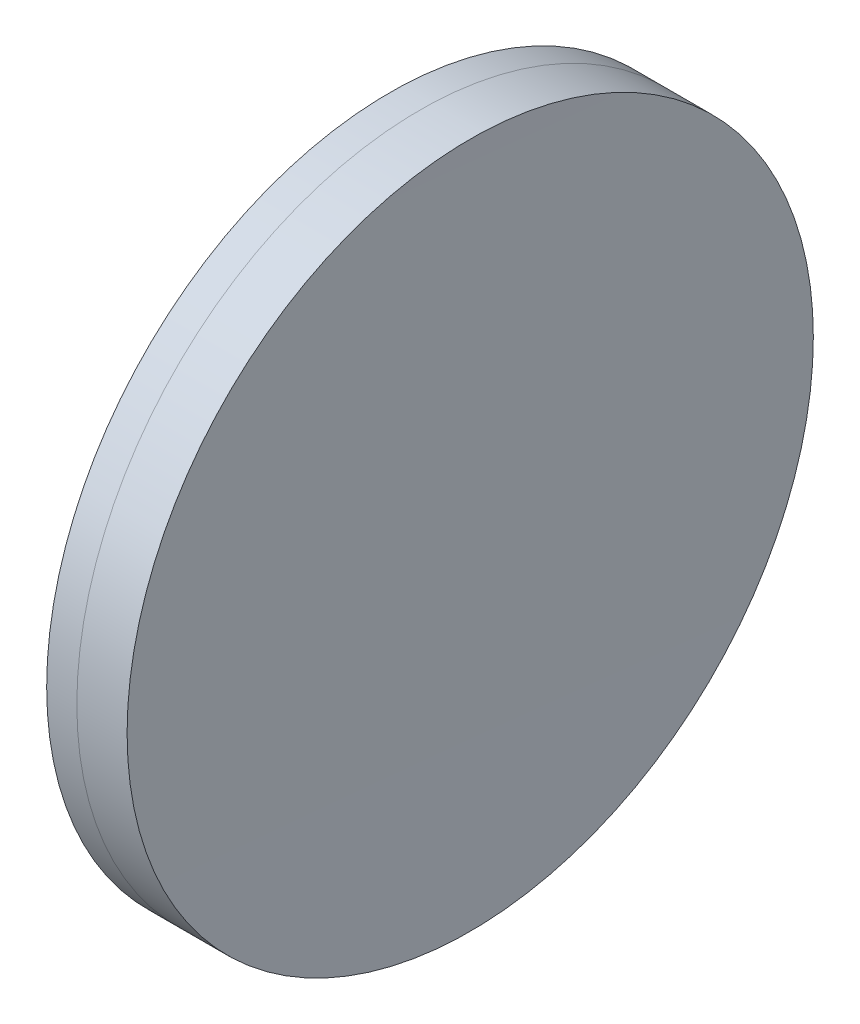
from build123d import *


with BuildPart() as part:
    # 草图1 one side → 旋转1 (revolve)
    with BuildSketch(Plane(origin=(0, 0, 0), x_dir=(1, 0, 0), z_dir=(0, 1, 0)), mode=Mode.PRIVATE) as revolve_1_sk:
        with BuildLine():
            ThreePointArc((-33.593845328, 25.4), (-34.236593471, 12.707228101), (-34.450924128, 0))
            Line((-34.450924128, 0), (-30.250924128, 0))
            ThreePointArc((-30.250924128, 0), (-30.528621285, 12.712126834), (-31.36118293, 25.4))
            Line((-31.36118293, 25.4), (-33.593845328, 25.4))
        make_face()
    revolve(revolve_1_sk.sketch.rotate(Axis((-402.021265573, 0, 0), (1, 0, 0)), 180), axis=Axis((-402.021265573, 0, 0), (1, 0, 0)))  # turned: the seam where the file's is


with BuildPart() as body_2:
    # 草图2 one side → 旋转3 (revolve)
    with BuildSketch(Plane(origin=(0, 0, 0), x_dir=(1, 0, 0), z_dir=(0, 1, 0)), mode=Mode.PRIVATE) as revolve_3_sk:
        with BuildLine():
            Line((-27.640069783, 25.4), (-31.36118293, 25.4))
            ThreePointArc((-31.36118293, 25.4), (-30.528621285, 12.712126834), (-30.250924128, 0))
            Line((-30.250924128, 0), (-27.750924128, 0))
            ThreePointArc((-27.750924128, 0), (-27.72321041, 12.700120951), (-27.640069783, 25.4))
        make_face()
    revolve(revolve_3_sk.sketch.rotate(Axis((-151.128475118, 0, 0), (1, 0, 0)), 180), axis=Axis((-151.128475118, 0, 0), (1, 0, 0)))  # turned: the seam where the file's is


solid = Compound([part.part, body_2.part])
